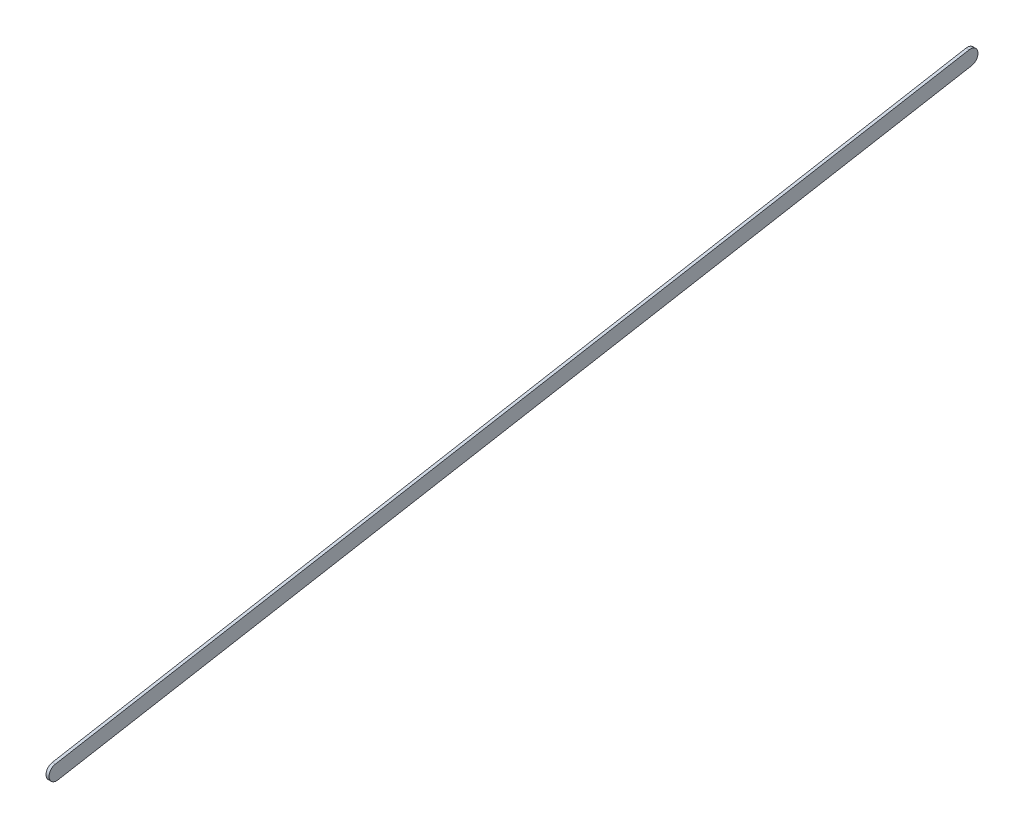
from build123d import *

# Parameters (mm, degrees)
BOSS_EXTRUDE1_DEPTH = 3


with BuildPart() as part:
    # Sketch1 → Boss-Extrude1 (new body)
    with BuildSketch(Plane(origin=(0, 0, 0), x_dir=(0, 0, -1), z_dir=(1, 0, 0))):
        with BuildLine():
            Line((1.307118196, -7.385217805), (-899.689453978, -166.853637659))
            ThreePointArc((-899.689453978, -166.853637659), (-908.381789979, -160.775538049), (-902.30369037, -152.083202049))
            Line((-902.30369037, -152.083202049), (-1.307118196, 7.385217805))
            ThreePointArc((-1.307118196, 7.385217805), (7.385217805, 1.307118196), (1.307118196, -7.385217805))
        make_face()
    extrude(amount=BOSS_EXTRUDE1_DEPTH)


solid = part.part
